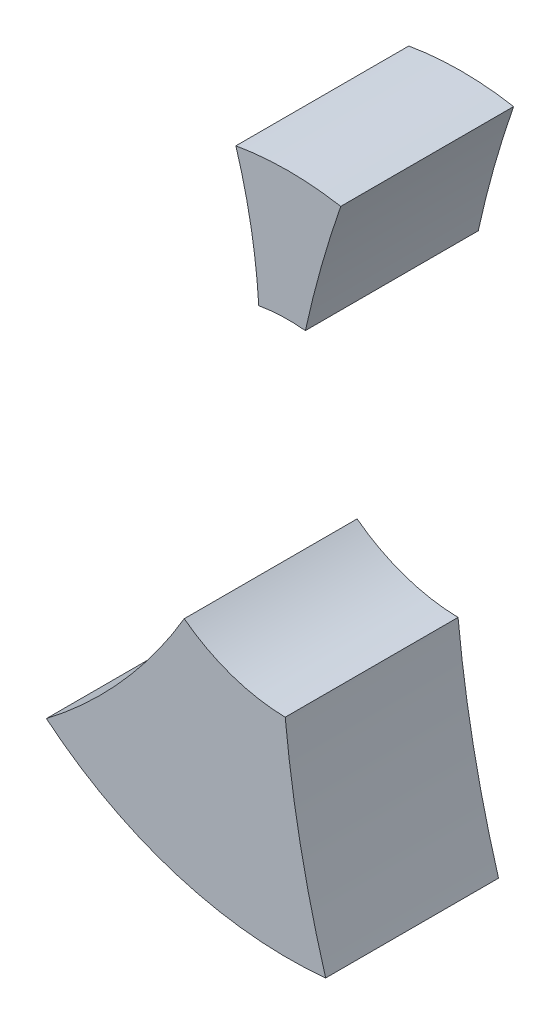
from build123d import *

# Parameters (mm, degrees)
SKETCH1_R           = 13.2
SKETCH1_R_2         = 6
BOSS_EXTRUDE1_DEPTH = 6
CUT_EXTRUDE1_DEPTH  = 7


with BuildPart() as part:
    # Sketch1 → Boss-Extrude1 (new body)
    with BuildSketch(Plane.XY):
        Circle(SKETCH1_R)
        Circle(SKETCH1_R_2, mode=Mode.SUBTRACT)
    extrude(amount=BOSS_EXTRUDE1_DEPTH)

    # Sketch2 → Cut-Extrude1 (cut, through all)
    with BuildSketch(Plane.XY.offset(6)):
        with BuildLine():
            ThreePointArc((-2.819851171, 12.895287487), (0, 13.2), (2.819851171, 12.895287487))
            ThreePointArc((2.819851171, 12.895287487), (73.562082536, -16.056153687), (1.819851171, 10.32))
            ThreePointArc((1.819851171, 10.32), (0, 10.479229852), (-1.819851171, 10.32))
            ThreePointArc((-1.819851171, 10.32), (-37.439635871, -2.029585062), (-2.819851171, 12.895287487))
        make_face()
    extrude(amount=-CUT_EXTRUDE1_DEPTH, mode=Mode.SUBTRACT)


solid = part.part
